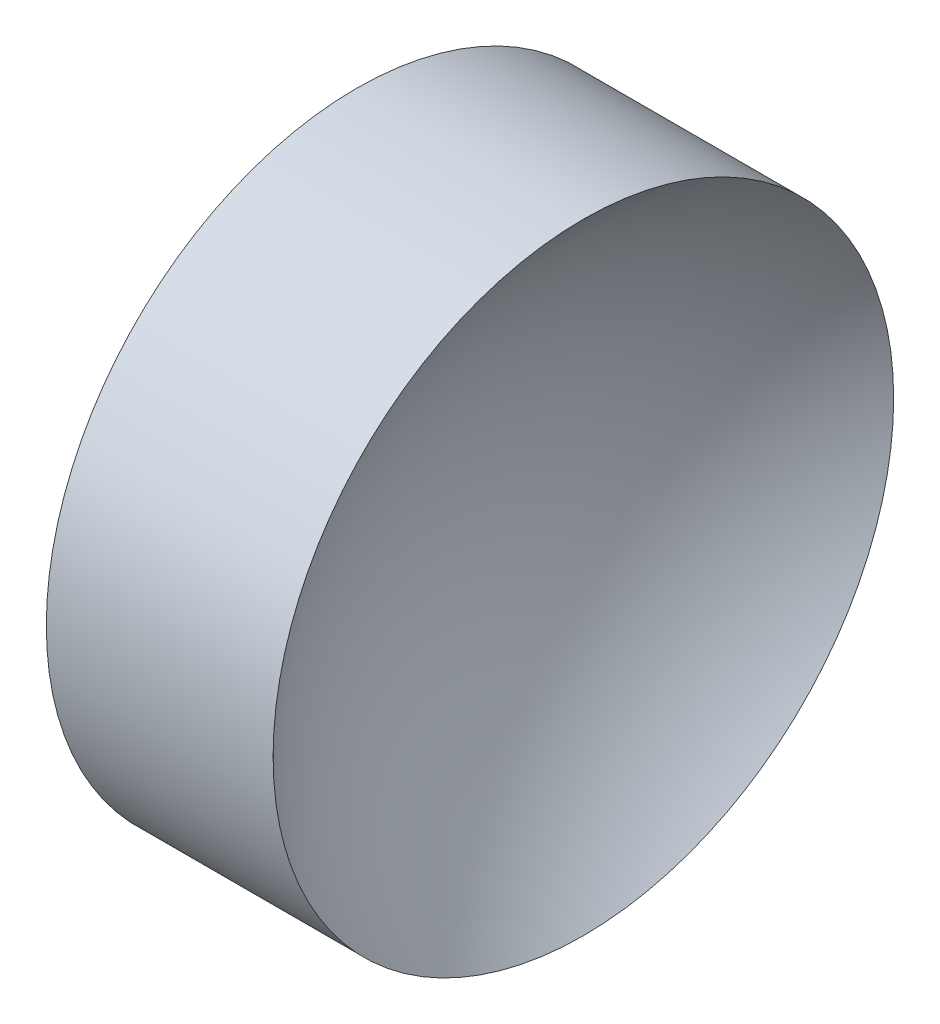
from build123d import *


with BuildPart() as part:
    # 草图1 → 旋转1 (revolve)
    with BuildSketch(Plane.XY, mode=Mode.PRIVATE) as revolve_1_sk:
        with BuildLine():
            Line((41.365827325, 26.062252183), (41.365827325, 31.062252183))
            Line((41.365827325, 31.062252183), (45.019898845, 31.062252183))
            ThreePointArc((45.019898845, 31.062252183), (43.427252014, 28.784384808), (42.865827325, 26.062252183))
            Line((42.865827325, 26.062252183), (41.365827325, 26.062252183))
        make_face()
    revolve(revolve_1_sk.sketch.rotate(Axis((39.736500013, 26.062252183, 0), (1, 0, 0)), 180), axis=Axis((39.736500013, 26.062252183, 0), (1, 0, 0)))  # turned: the seam where the file's is


solid = part.part
